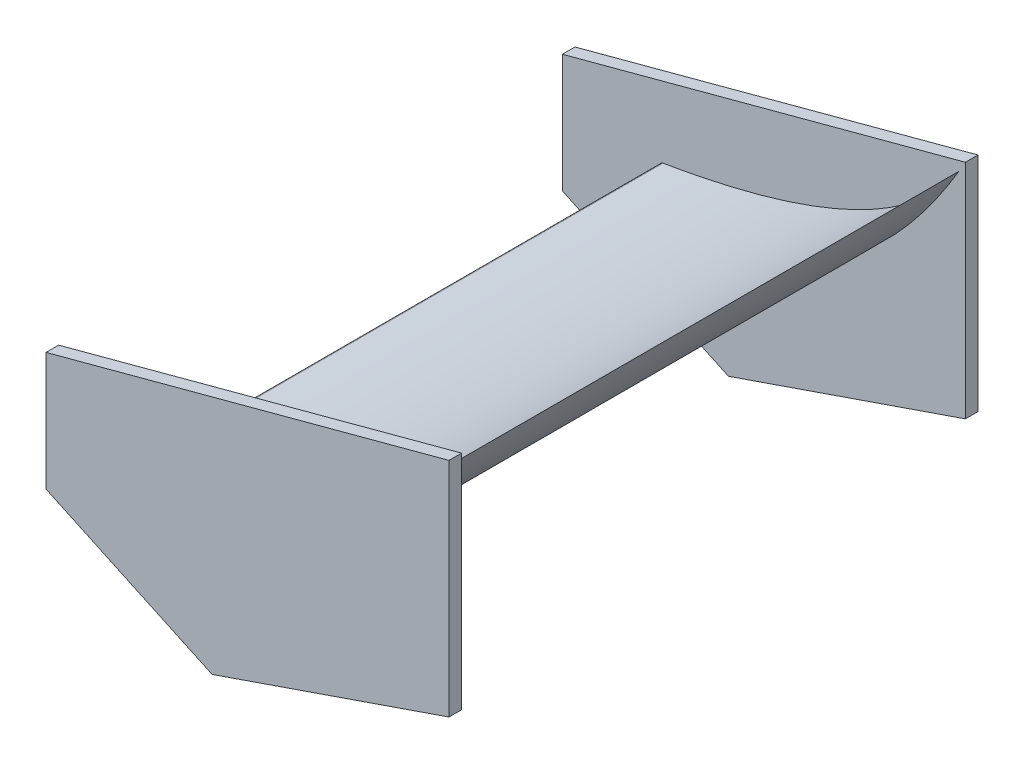
from build123d import *

# Parameters (mm, degrees)
BOSS_EXTRUDE4_START = 500
BOSS_EXTRUDE4_DEPTH = 25
BOSS_EXTRUDE5_DEPTH = 500


with BuildPart() as part:
    # Sketch3 → Boss-Extrude4 (new body)
    with BuildSketch(Plane.XY.offset(BOSS_EXTRUDE4_START)):
        Polygon((980.277216874, 1103.111612785), (980.277216874, 661.929431671), (510, 500), (180.277216874, 653.75225884), (180.277216874, 888.75225884), align=None)
    extrude(amount=BOSS_EXTRUDE4_DEPTH)


with BuildPart() as body_2:
    # Mirror6: mirrored copy
    add(part.part.mirror(Plane.XY))


with BuildPart() as body_3:
    # Sketch4 → Boss-Extrude5 (new body, symmetric)
    with BuildSketch(Plane.XY):
        with BuildLine():
            add(Edge.make_bspline(
                [(375.337243968, 791.193870862), (713.99043586, 657.058073837), (967.403573874, 1081.113118762)],
                knots=[0, 0, 0, 0.975124618, 0.975124618, 0.975124618], degree=2))
            add(Edge.make_bspline(
                [(967.403573874, 1081.113118762), (837.573835199, 877.51909723), (380.277216874, 801.555806392)],
                knots=[0.050458865, 0.050458865, 0.050458865, 1, 1, 1], degree=2))
            ThreePointArc((380.277216874, 801.555806392), (375.105625682, 797.662807865), (375.337243968, 791.193870862))
        make_face()
    extrude(amount=BOSS_EXTRUDE5_DEPTH, both=True)


solid = Compound([part.part, body_2.part, body_3.part])
